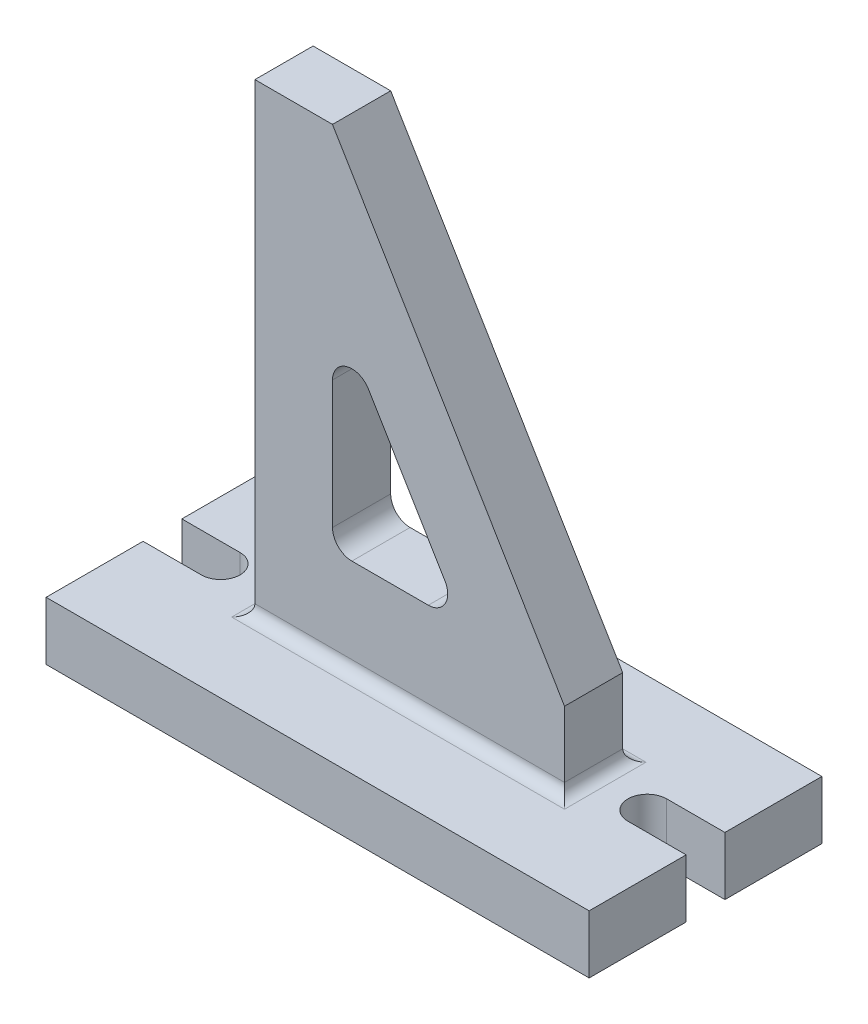
from build123d import *

# Parameters (mm, degrees)
SKETCH1_W                  = 177.8
SKETCH1_H                  = 76.2
MILLING_SUPPORT_BASE_DEPTH = 19.05
BOLT_SLOT_LEFT_END_DEPTH   = 20.05
BOLT_SLOT_RIGHT_END_DEPTH  = 20.05
OUTER_TRIANGLE_DEPTH       = 9.525
INNER_TRIANGLE_DEPTH       = 48.625
FILLET_AT_TRIANGLE_BASE_R  = 3.81


with BuildPart() as part:
    # Sketch1 → Milling Support Base (new body)
    with BuildSketch(Plane(origin=(0, 0, 0), x_dir=(1, 0, 0), z_dir=(0, 1, 0))):
        with Locations((12.7, 0)):
            Rectangle(SKETCH1_W, SKETCH1_H)
    extrude(amount=-MILLING_SUPPORT_BASE_DEPTH)

    # Sketch2 → Bolt Slot Left End (cut, through all)
    with BuildSketch(Plane(origin=(0, 0, 0), x_dir=(1, 0, 0), z_dir=(0, 1, 0))):
        with BuildLine():
            Line((-76.2, 6.35), (-57.15, 6.35))
            ThreePointArc((-57.15, 6.35), (-50.8, 0), (-57.15, -6.35))
            Line((-57.15, -6.35), (-76.2, -6.35))
            Line((-76.2, -6.35), (-76.2, 6.35))
        make_face()
    extrude(amount=-BOLT_SLOT_LEFT_END_DEPTH, mode=Mode.SUBTRACT)

    # Sketch3 → Bolt Slot Right End (cut, through all)
    with BuildSketch(Plane.XZ.offset(19.05)):
        with BuildLine():
            Line((101.6, 6.35), (82.55, 6.35))
            ThreePointArc((82.55, 6.35), (76.2, 0), (82.55, -6.35))
            Line((82.55, -6.35), (101.6, -6.35))
            Line((101.6, -6.35), (101.6, 6.35))
        make_face()
    extrude(amount=-BOLT_SLOT_RIGHT_END_DEPTH, mode=Mode.SUBTRACT)

    # Sketch4 → Outer Triangle (add, symmetric)
    with BuildSketch(Plane.XY):
        Polygon((-36.408550143, 0), (-36.408550143, 152.4), (-11.008550143, 152.4), (64.959238023, 25.4), (64.959238023, 0), align=None)
    extrude(amount=OUTER_TRIANGLE_DEPTH, both=True)

    # Sketch5 → Inner Triangle (cut, through all)
    with BuildSketch(Plane.XY.offset(9.525)):
        with BuildLine():
            Line((-4.658550143, 31.75), (20.365749185, 31.75))
            ThreePointArc((20.365749185, 31.75), (25.889412512, 34.967645701), (25.81522023, 41.359718598))
            Line((25.81522023, 41.359718598), (0.790920902, 83.194371039))
            ThreePointArc((0.790920902, 83.194371039), (-6.349460972, 86.055381202), (-11.008550143, 79.934652441))
            Line((-11.008550143, 79.934652441), (-11.008550143, 38.1))
            ThreePointArc((-11.008550143, 38.1), (-9.148678203, 33.609871939), (-4.658550143, 31.75))
        make_face()
    extrude(amount=-INNER_TRIANGLE_DEPTH, mode=Mode.SUBTRACT)

    # Fillet at Triangle base
    fillet_at_triangle_base_edges = [part.edges().sort_by_distance(p)[0] for p in [
        (14.27534394, 0, -9.525),
        (-36.408550143, 0, 0),
        (64.959238023, 0, 0),
        (14.27534394, 0, 9.525),
    ]]
    fillet(fillet_at_triangle_base_edges, radius=FILLET_AT_TRIANGLE_BASE_R)


solid = part.part
